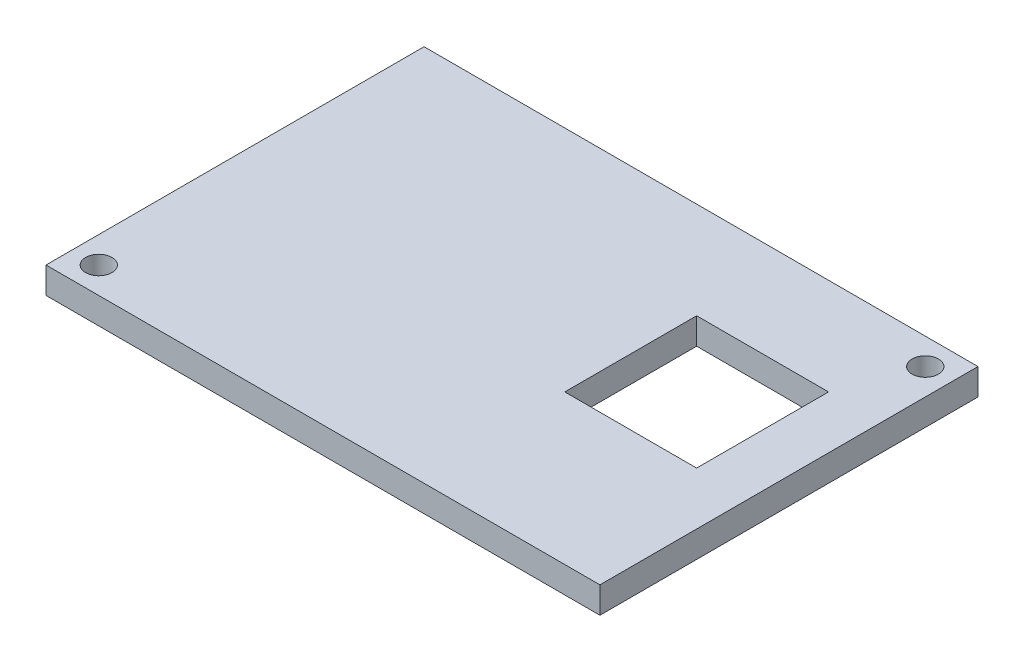
from build123d import *

# Parameters (mm, degrees)
SKETCH2_W           = 63
SKETCH2_H           = 43
BOSS_EXTRUDE1_DEPTH = 3
SKETCH3_R           = 1.5
CUT_EXTRUDE1_DEPTH  = 3
SKETCH4_R           = 1.5
CUT_EXTRUDE2_DEPTH  = 3
SKETCH5_W           = 15
SKETCH5_H           = 15
CUT_EXTRUDE3_DEPTH  = 3


with BuildPart() as part:
    # Sketch2 → Boss-Extrude1 (new body)
    with BuildSketch(Plane(origin=(0, 0, 0), x_dir=(1, 0, 0), z_dir=(0, 1, 0))):
        with Locations((-0.384353741, 1.170068027)):
            Rectangle(SKETCH2_W, SKETCH2_H)
    extrude(amount=BOSS_EXTRUDE1_DEPTH)

    # Sketch3 → Cut-Extrude1 (cut)
    with BuildSketch(Plane(origin=(0, 3, 0), x_dir=(1, 0, 0), z_dir=(0, 1, 0))):
        with Locations((28.115646259, 19.670068027)):
            Circle(SKETCH3_R)
    extrude(amount=-CUT_EXTRUDE1_DEPTH, mode=Mode.SUBTRACT)

    # Sketch4 → Cut-Extrude2 (cut)
    with BuildSketch(Plane(origin=(0, 3, 0), x_dir=(1, 0, 0), z_dir=(0, 1, 0))):
        with Locations((-28.884353741, -17.329931973)):
            Circle(SKETCH4_R)
    extrude(amount=-CUT_EXTRUDE2_DEPTH, mode=Mode.SUBTRACT)

    # Sketch5 → Cut-Extrude3 (cut)
    with BuildSketch(Plane(origin=(0, 3, 0), x_dir=(1, 0, 0), z_dir=(0, 1, 0))):
        with Locations((17.615646259, 4.170068027)):
            Rectangle(SKETCH5_W, SKETCH5_H)
    extrude(amount=-CUT_EXTRUDE3_DEPTH, mode=Mode.SUBTRACT)


solid = part.part
